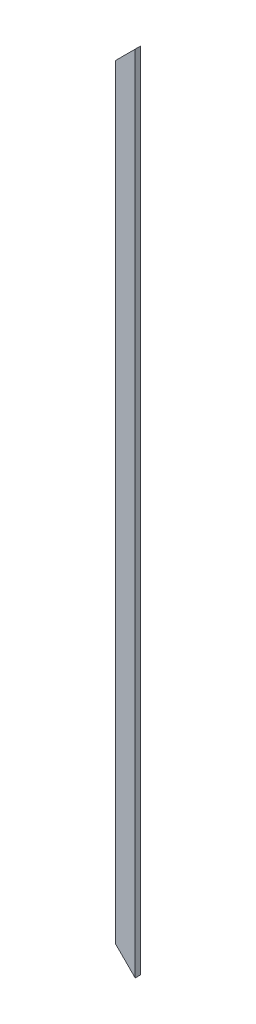
from build123d import *

# Parameters (mm, degrees)
SKETCH1_W               = 139.7
SKETCH1_H               = 38.1
BOSS_EXTRUDE1_DEPTH     = 5664.2
CUT_EXTRUDE1_DEPTH      = 1
CUT_EXTRUDE1_DEPTH_BACK = 39.1


with BuildPart() as part:
    # Sketch1 → Boss-Extrude1 (new body)
    with BuildSketch(Plane(origin=(0, 0, 0), x_dir=(1, 0, 0), z_dir=(0, 1, 0))):
        Rectangle(SKETCH1_W, SKETCH1_H)
    extrude(amount=BOSS_EXTRUDE1_DEPTH)

    # Sketch2 → Cut-Extrude1 (cut, two sides)
    with BuildSketch(Plane.XY.offset(19.05)) as cut_extrude1_sk:
        Polygon((69.85, 5664.2), (-69.85, 5524.5), (-69.85, 5664.2), align=None)
        Polygon((69.85, 0), (-69.85, 139.7), (-69.85, 0), align=None)
    extrude(amount=CUT_EXTRUDE1_DEPTH, mode=Mode.SUBTRACT)
    extrude(cut_extrude1_sk.sketch, amount=-CUT_EXTRUDE1_DEPTH_BACK, mode=Mode.SUBTRACT)


solid = part.part
